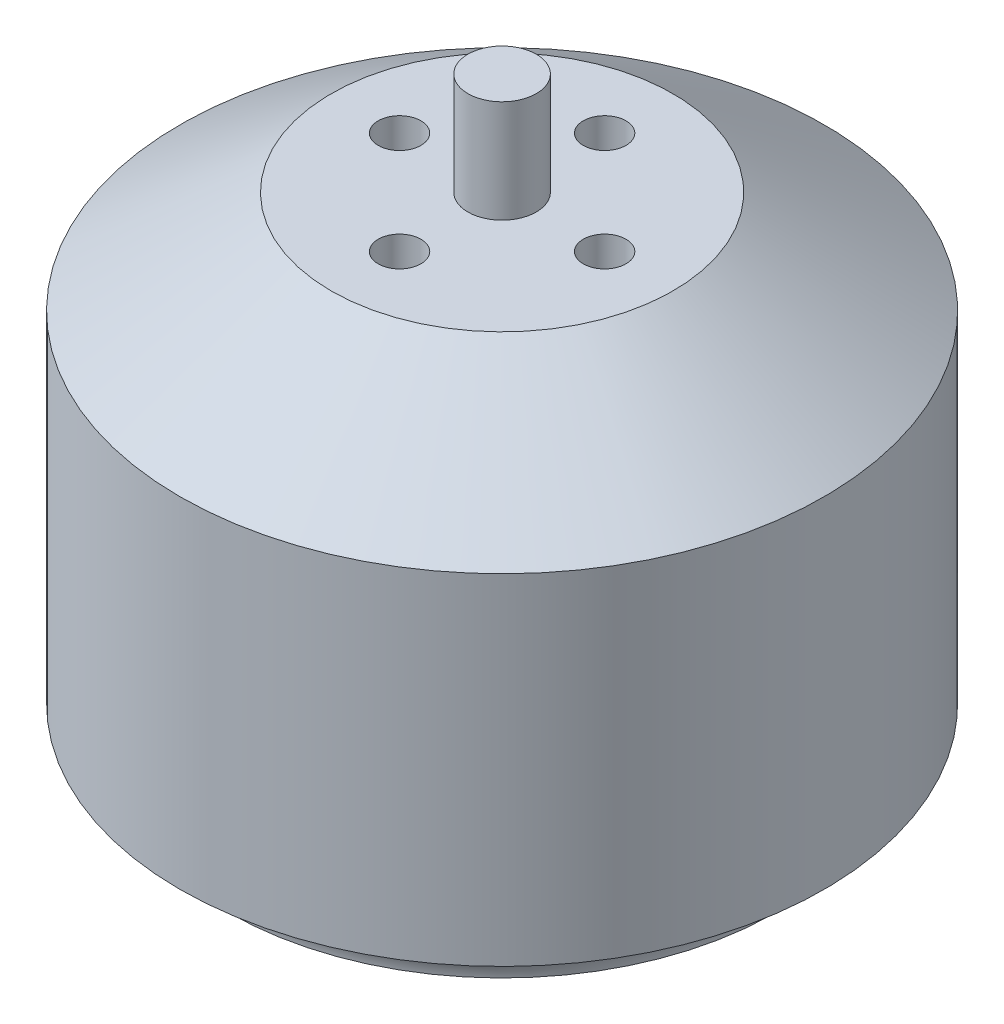
from build123d import *

# Parameters (mm, degrees)
SKETCH1_R                 = 18.85
BOSS_EXTRUDE1_DEPTH       = 28.5
SKETCH2_R                 = 2
BOSS_EXTRUDE2_DEPTH       = 6
SKETCH3_R                 = 2
BOSS_EXTRUDE3_DEPTH       = 2.6
M3X0_5_TAPPED_HOLE1_D     = 2.5
M3X0_5_TAPPED_HOLE1_DEPTH = 1.648924226
M3X0_5_TAPPED_HOLE1_TIP   = 0.751075774
M3X0_5_TAPPED_HOLE2_D     = 2.5
M3X0_5_TAPPED_HOLE2_DEPTH = 5.248924226
M3X0_5_TAPPED_HOLE2_TIP   = 0.751075774


with BuildPart() as part:
    # Sketch1 → Boss-Extrude1 (new body)
    with BuildSketch(Plane(origin=(0, 0, 0), x_dir=(1, 0, 0), z_dir=(0, 1, 0))):
        Circle(SKETCH1_R)
    extrude(amount=BOSS_EXTRUDE1_DEPTH)

    # Sketch2 → Boss-Extrude2 (add)
    with BuildSketch(Plane(origin=(0, 28.5, 0), x_dir=(1, 0, 0), z_dir=(0, 1, 0))):
        Circle(SKETCH2_R)
    extrude(amount=BOSS_EXTRUDE2_DEPTH)

    # Sketch3 → Boss-Extrude3 (add)
    with BuildSketch(Plane.XZ):
        Circle(SKETCH3_R)
    extrude(amount=BOSS_EXTRUDE3_DEPTH)

    # M3x0.5 Tapped Hole1
    with Locations(Plane(origin=(0, 0, 9.5), x_dir=(0, 0, -1), z_dir=(0, -1, 0))):
        with Locations((0, 0), (9.5, 8), (9.5, 12.5), (19, 0), (9.5, -8), (9.5, -12.5)):
            Hole(M3X0_5_TAPPED_HOLE1_D / 2, depth=M3X0_5_TAPPED_HOLE1_DEPTH)
            with Locations((0, 0, -(M3X0_5_TAPPED_HOLE1_DEPTH + M3X0_5_TAPPED_HOLE1_TIP / 2))):  # 118° drill point
                Cone(0, M3X0_5_TAPPED_HOLE1_D / 2, M3X0_5_TAPPED_HOLE1_TIP, mode=Mode.SUBTRACT)

    # Sketch10 → Cut-Revolve1 (revolve, cut)
    with BuildSketch(Plane.XY):
        Polygon((-18.85, 28.5), (-10, 28.5), (-18.85, 22.5), align=None)
        with BuildLine():
            Line((-18.85, 2.6), (-18.85, 0))
            Line((-18.85, 0), (-16, 0))
            ThreePointArc((-16, 0), (-16.921107831, 1.852343339), (-18.85, 2.6))
        make_face()
    revolve(axis=Axis((0, 28.5, 0), (0, -1, 0)), mode=Mode.SUBTRACT)

    # M3x0.5 Tapped Hole2
    with Locations(Plane(origin=(0, 28.5, -6), x_dir=(0, 0, 1), z_dir=(0, 1, 0))):
        with Locations((0, 0), (6, 6), (12, 0), (6, -6)):
            Hole(M3X0_5_TAPPED_HOLE2_D / 2, depth=M3X0_5_TAPPED_HOLE2_DEPTH)
            with Locations((0, 0, -(M3X0_5_TAPPED_HOLE2_DEPTH + M3X0_5_TAPPED_HOLE2_TIP / 2))):  # 118° drill point
                Cone(0, M3X0_5_TAPPED_HOLE2_D / 2, M3X0_5_TAPPED_HOLE2_TIP, mode=Mode.SUBTRACT)


solid = part.part
